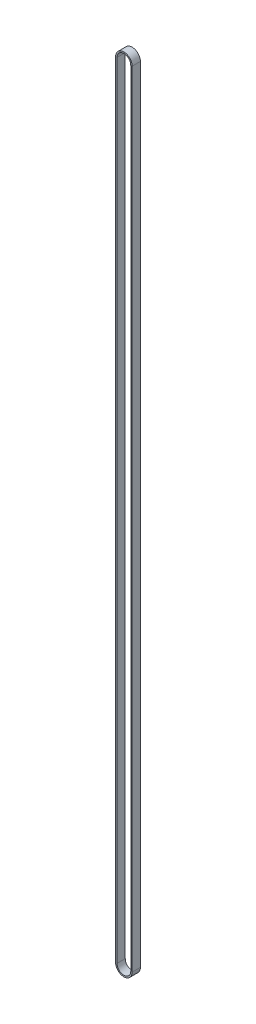
from build123d import *

# Parameters (mm, degrees)
BOSS_EXTRUDE1_DEPTH = 6


with BuildPart() as part:
    # Sketch1 → Boss-Extrude1 (new body)
    with BuildSketch(Plane.XY):
        with BuildLine():
            Line((-6, 569.99997537), (-6, 0))
            ThreePointArc((-6, 0), (0, -6), (6, 0))
            Line((6, 0), (6, 569.99997537))
            ThreePointArc((6, 569.99997537), (0, 575.99997537), (-6, 569.99997537))
        make_face()
        with BuildLine():
            Line((-5, 569.99997537), (-5, 0))
            ThreePointArc((-5, 0), (0, -5), (5, 0))
            Line((5, 0), (5, 569.99997537))
            ThreePointArc((5, 569.99997537), (0, 574.99997537), (-5, 569.99997537))
        make_face(mode=Mode.SUBTRACT)
    extrude(amount=BOSS_EXTRUDE1_DEPTH)


solid = part.part
